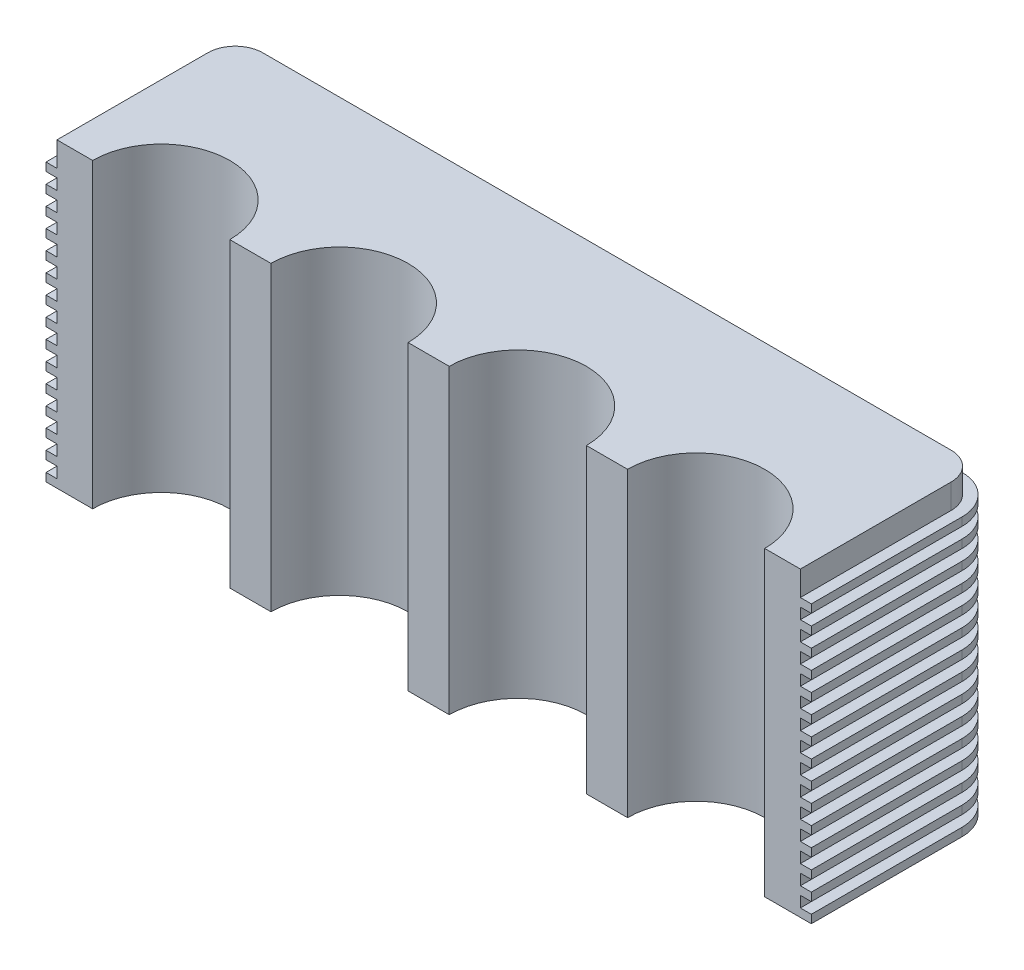
from build123d import *

# Parameters (mm, degrees)
BOSS_EXTRUDE1_DEPTH = 110
BOSS_EXTRUDE2_DEPTH = 3
LPATTERN2_COUNT     = 15
LPATTERN2_PITCH     = 7


with BuildPart() as part:
    # Sketch1 → Boss-Extrude1 (new body)
    with BuildSketch(Plane(origin=(0, 0, 0), x_dir=(1, 0, 0), z_dir=(0, 1, 0))):
        with BuildLine():
            Line((0, 0), (13, 0))
            ThreePointArc((13, 0), (38, 25), (63, 0))
            Line((63, 0), (78, 0))
            ThreePointArc((78, 0), (103, 25), (128, 0))
            Line((128, 0), (143, 0))
            ThreePointArc((143, 0), (168, 25), (193, 0))
            Line((193, 0), (208, 0))
            ThreePointArc((208, 0), (233, 25), (258, 0))
            Line((258, 0), (271, 0))
            Line((271, 0), (271, 55))
            ThreePointArc((271, 55), (268.071067812, 62.071067812), (261, 65))
            Line((261, 65), (10, 65))
            ThreePointArc((10, 65), (2.928932188, 62.071067812), (0, 55))
            Line((0, 55), (0, 0))
        make_face()
    extrude(amount=BOSS_EXTRUDE1_DEPTH)

    # Sketch2 → Boss-Extrude2 (add)
    with BuildSketch(Plane(origin=(0, 0, 0), x_dir=(1, 0, 0), z_dir=(0, 1, 0))):
        with BuildLine():
            Line((271, 0), (271, 55))
            ThreePointArc((271, 55), (268.071067812, 62.071067812), (261, 65))
            Line((261, 65), (10, 65))
            ThreePointArc((10, 65), (2.928932188, 62.071067812), (0, 55))
            Line((0, 55), (0, 0))
            Line((0, 0), (-4, 0))
            Line((-4, 0), (-4, 55))
            ThreePointArc((-4, 55), (0.100505063, 64.899494937), (10, 69))
            Line((10, 69), (261, 69))
            ThreePointArc((261, 69), (270.899494937, 64.899494937), (275, 55))
            Line((275, 55), (275, 0))
            Line((275, 0), (271, 0))
        make_face()
    boss_extrude2 = extrude(amount=BOSS_EXTRUDE2_DEPTH)

    # LPattern2: Boss-Extrude2 ×15
    with Locations(*[(0, i * LPATTERN2_PITCH, 0) for i in range(1, LPATTERN2_COUNT)]):
        add(boss_extrude2)


solid = part.part
